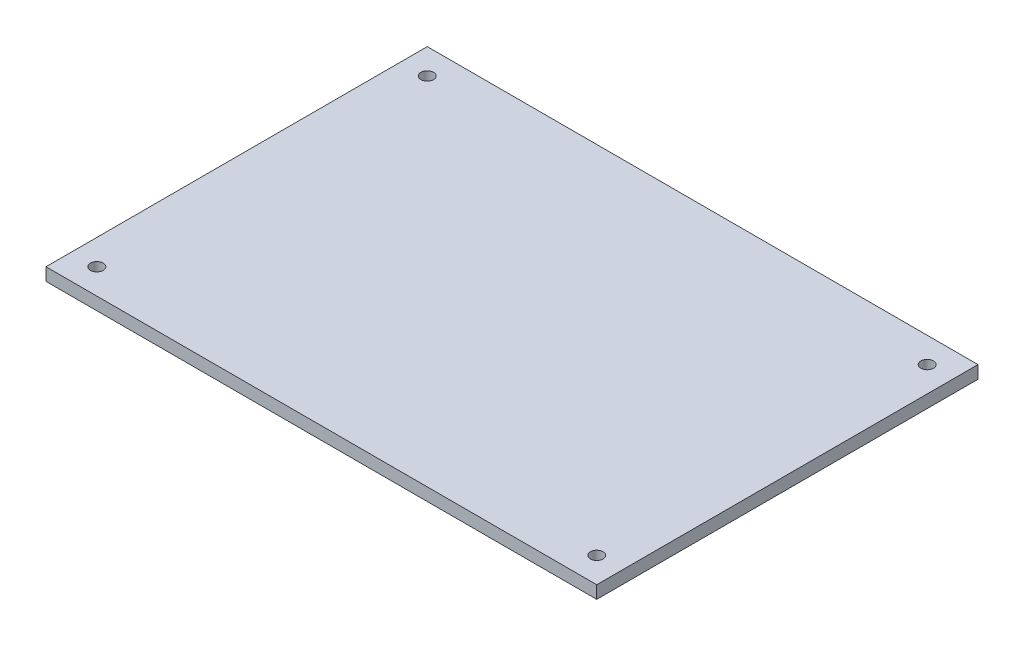
from build123d import *

# Parameters (mm, degrees)
SKETCH2_W            = 130
SKETCH2_H            = 90
BOSS_EXTRUDE1_DEPTH  = 3
SKETCH3_R            = 1.5
CUT_EXTRUDE1_DEPTH   = 4
LPATTERN1_COUNT      = 2
LPATTERN1_PITCH      = 78
LPATTERN1_COUNT_DIR2 = 2
LPATTERN1_PITCH_DIR2 = 118


with BuildPart() as part:
    # Sketch2 → Boss-Extrude1 (new body)
    with BuildSketch(Plane(origin=(0, 0, 0), x_dir=(1, 0, 0), z_dir=(0, 1, 0))):
        Rectangle(SKETCH2_W, SKETCH2_H)
    extrude(amount=BOSS_EXTRUDE1_DEPTH)

    # Sketch3 → Cut-Extrude1 (cut, through all)
    with BuildSketch(Plane(origin=(0, 3, 0), x_dir=(1, 0, 0), z_dir=(0, 1, 0))):
        with Locations((59, -39)):
            Circle(SKETCH3_R)
    cut_extrude1 = extrude(amount=-CUT_EXTRUDE1_DEPTH, mode=Mode.SUBTRACT)

    # LPattern1: Cut-Extrude1 2 × 2
    with Locations(*[(-j * LPATTERN1_PITCH_DIR2, 0, -i * LPATTERN1_PITCH) for i in range(LPATTERN1_COUNT) for j in range(LPATTERN1_COUNT_DIR2) if (i, j) != (0, 0)]):
        add(cut_extrude1, mode=Mode.SUBTRACT)


solid = part.part
